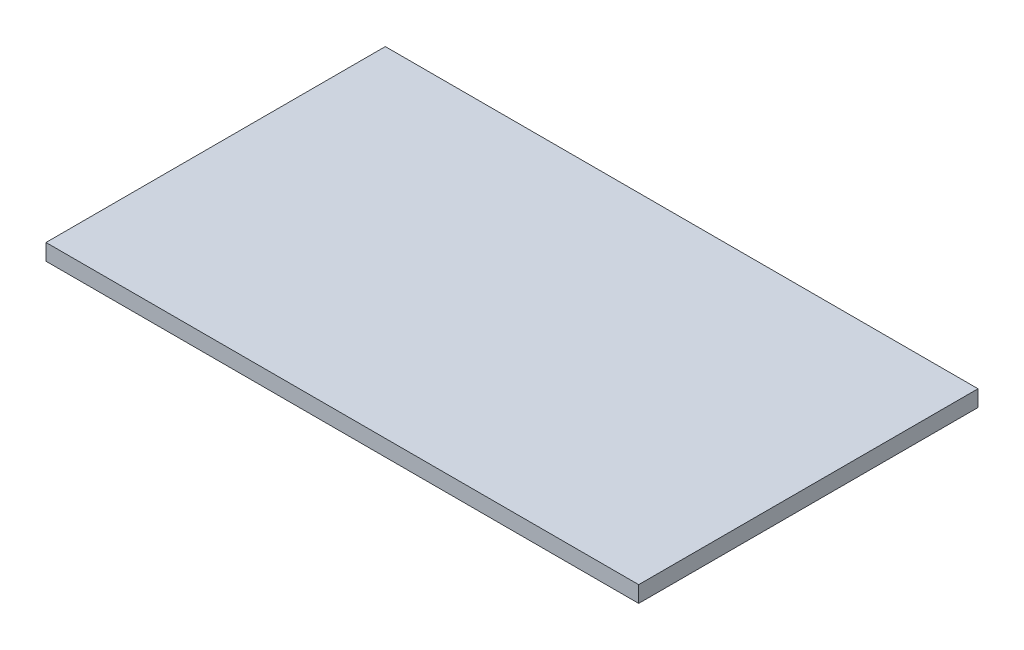
from build123d import *

# Parameters (mm, degrees)
SKETCH1_W           = 109.238
SKETCH1_H           = 62.54
BOSS_EXTRUDE1_DEPTH = 3
SKETCH2_W           = 107.238
SKETCH2_H           = 60.54
SKETCH2_W_2         = 105.238
SKETCH2_H_2         = 58.54
BOSS_EXTRUDE2_DEPTH = 3
BOSS_EXTRUDE2_TAPER = 45


with BuildPart() as part:
    # Sketch1 → Boss-Extrude1 (new body)
    with BuildSketch(Plane(origin=(0, 0, 0), x_dir=(1, 0, 0), z_dir=(0, 1, 0))):
        Rectangle(SKETCH1_W, SKETCH1_H)
    extrude(amount=BOSS_EXTRUDE1_DEPTH)

    # Sketch2 → Boss-Extrude2 (add)
    with BuildSketch(Plane.XZ):
        Rectangle(SKETCH2_W, SKETCH2_H)
        Rectangle(SKETCH2_W_2, SKETCH2_H_2, mode=Mode.SUBTRACT)
    extrude(amount=BOSS_EXTRUDE2_DEPTH, taper=BOSS_EXTRUDE2_TAPER)


solid = part.part
